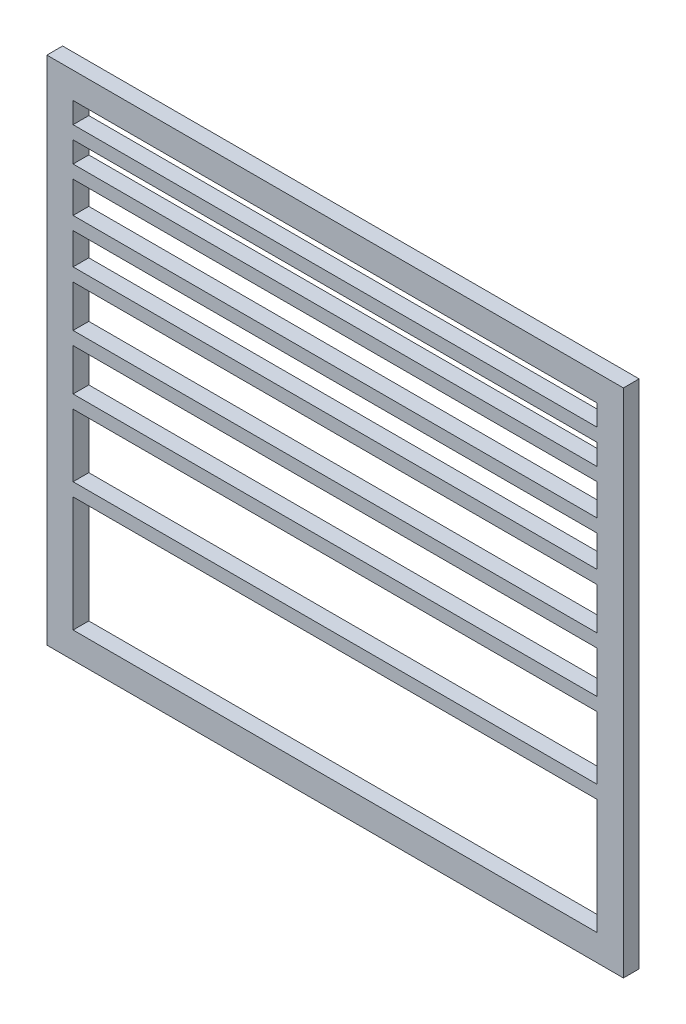
from build123d import *

# Parameters (mm, degrees)
SKETCH_1_W      = 220
SKETCH_1_H      = 195
SKETCH_1_W_2    = 200
SKETCH_1_H_2    = 8
SKETCH_1_H_3    = 12
SKETCH_1_H_4    = 16
SKETCH_1_H_5    = 24
SKETCH_1_H_6    = 44
EXTRUDE_1_DEPTH = 6


with BuildPart() as part:
    # Эскиз1 → Бобышка-Вытянуть1 (new body)
    with BuildSketch(Plane.XY):
        with Locations((0, 26.5)):
            Rectangle(SKETCH_1_W, SKETCH_1_H)
        with Locations((0, 110)):
            Rectangle(SKETCH_1_W_2, SKETCH_1_H_2, mode=Mode.SUBTRACT)
        with Locations((0, 97)):
            Rectangle(SKETCH_1_W_2, SKETCH_1_H_2, mode=Mode.SUBTRACT)
        with Locations((0, 82)):
            Rectangle(SKETCH_1_W_2, SKETCH_1_H_3, mode=Mode.SUBTRACT)
        with Locations((0, 65)):
            Rectangle(SKETCH_1_W_2, SKETCH_1_H_3, mode=Mode.SUBTRACT)
        with Locations((0, 46)):
            Rectangle(SKETCH_1_W_2, SKETCH_1_H_4, mode=Mode.SUBTRACT)
        with Locations((0, 25)):
            Rectangle(SKETCH_1_W_2, SKETCH_1_H_4, mode=Mode.SUBTRACT)
        Rectangle(SKETCH_1_W_2, SKETCH_1_H_5, mode=Mode.SUBTRACT)
        with Locations((0, -39)):
            Rectangle(SKETCH_1_W_2, SKETCH_1_H_6, mode=Mode.SUBTRACT)
    extrude(amount=EXTRUDE_1_DEPTH)


solid = part.part
